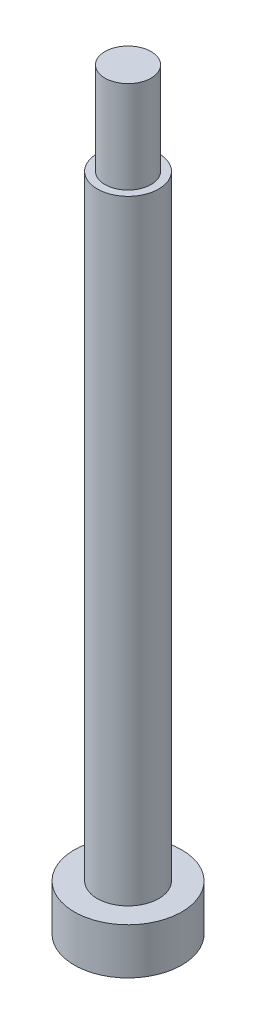
from build123d import *

# Parameters (mm, degrees)
SKETCH_1_R      = 2
EXTRUDE_1_DEPTH = 40
SKETCH_2_R      = 1.5
EXTRUDE_2_DEPTH = 6
SKETCH_3_R      = 3.5
EXTRUDE_3_DEPTH = 3


with BuildPart() as part:
    # 草图1 → 凸台-拉伸1 (new body)
    with BuildSketch(Plane(origin=(0, 0, 0), x_dir=(1, 0, 0), z_dir=(0, 1, 0))):
        Circle(SKETCH_1_R)
    extrude(amount=EXTRUDE_1_DEPTH)

    # 草图2 → 凸台-拉伸2 (add)
    with BuildSketch(Plane(origin=(0, 40, 0), x_dir=(1, 0, 0), z_dir=(0, 1, 0))):
        Circle(SKETCH_2_R)
    extrude(amount=EXTRUDE_2_DEPTH)

    # 草图3 → 凸台-拉伸3 (add)
    with BuildSketch(Plane.XZ):
        Circle(SKETCH_3_R)
    extrude(amount=EXTRUDE_3_DEPTH)


solid = part.part
